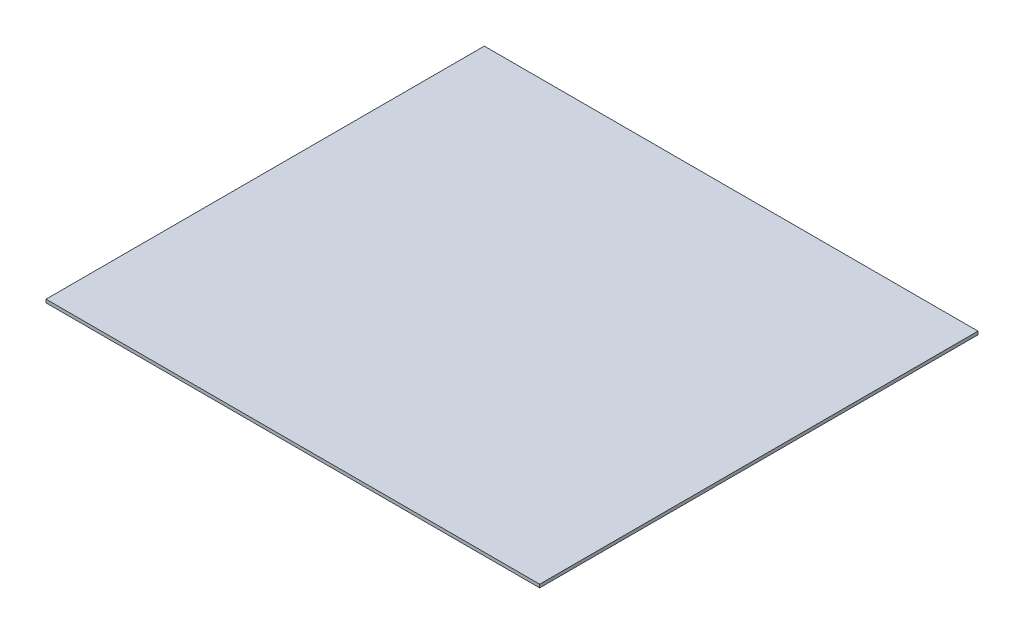
from build123d import *

# Parameters (mm, degrees)
SKETCH_1_W      = 461.769145362
SKETCH_1_H      = 3
EXTRUDE_1_DEPTH = 410


with BuildPart() as part:
    # Эскиз1 → Бобышка-Вытянуть1 (new body)
    with BuildSketch(Plane.XY):
        with Locations((0, 1.5)):
            Rectangle(SKETCH_1_W, SKETCH_1_H)
    extrude(amount=-EXTRUDE_1_DEPTH)


solid = part.part
